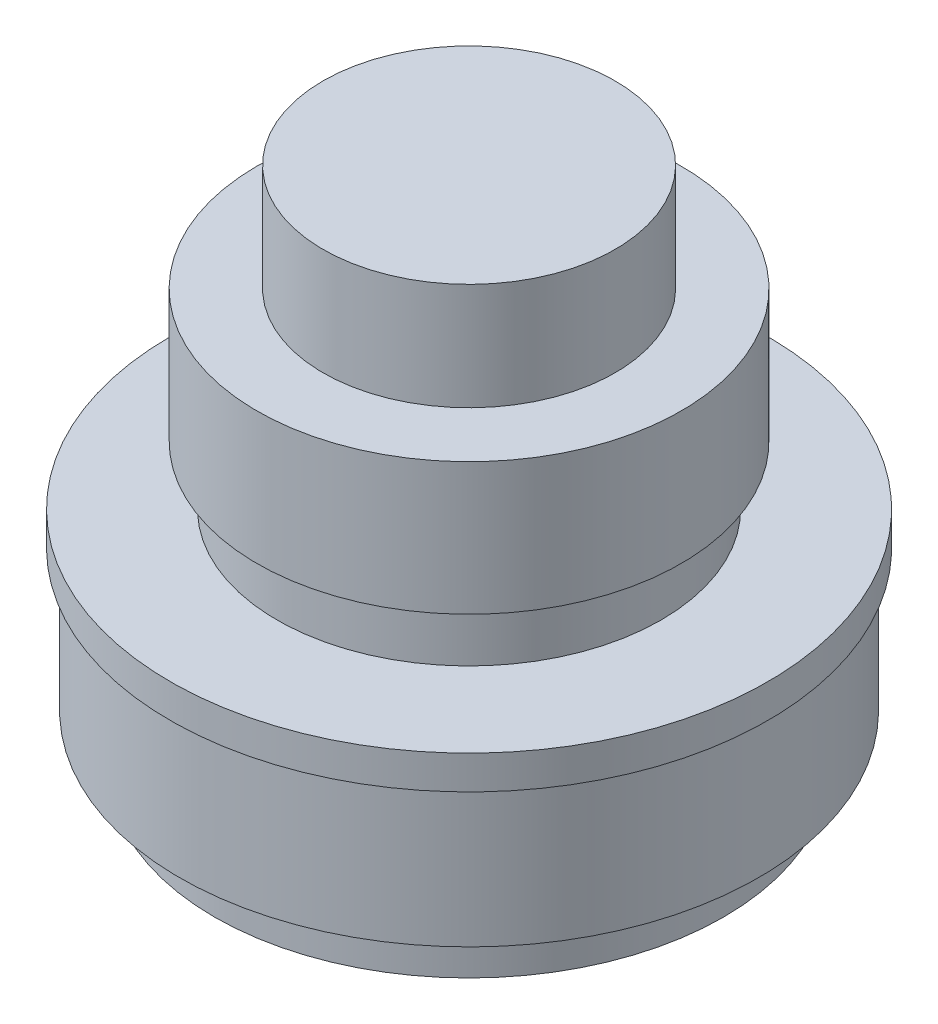
from build123d import *


with BuildPart() as part:
    # Sketch3 → Revolve1 (revolve)
    with BuildSketch(Plane.XY):
        Polygon((0, 5.662167056), (0, -39.937832944), (-22.155, -39.937832944), (-22.155, -35.443518029), (-25.2, -35.443518029), (-25.2, -23.193518029), (-26.005, -23.193518029), (-26.005, -20.267832944), (-16.715, -20.267832944), (-16.715, -15.137832944), (-18.46, -15.137832944), (-18.46, -3.637832944), (-12.71, -3.637832944), (-12.71, 5.662167056), align=None)
    revolve(axis=Axis((0, 5.662167056, 0), (0, -1, 0)))


solid = part.part
